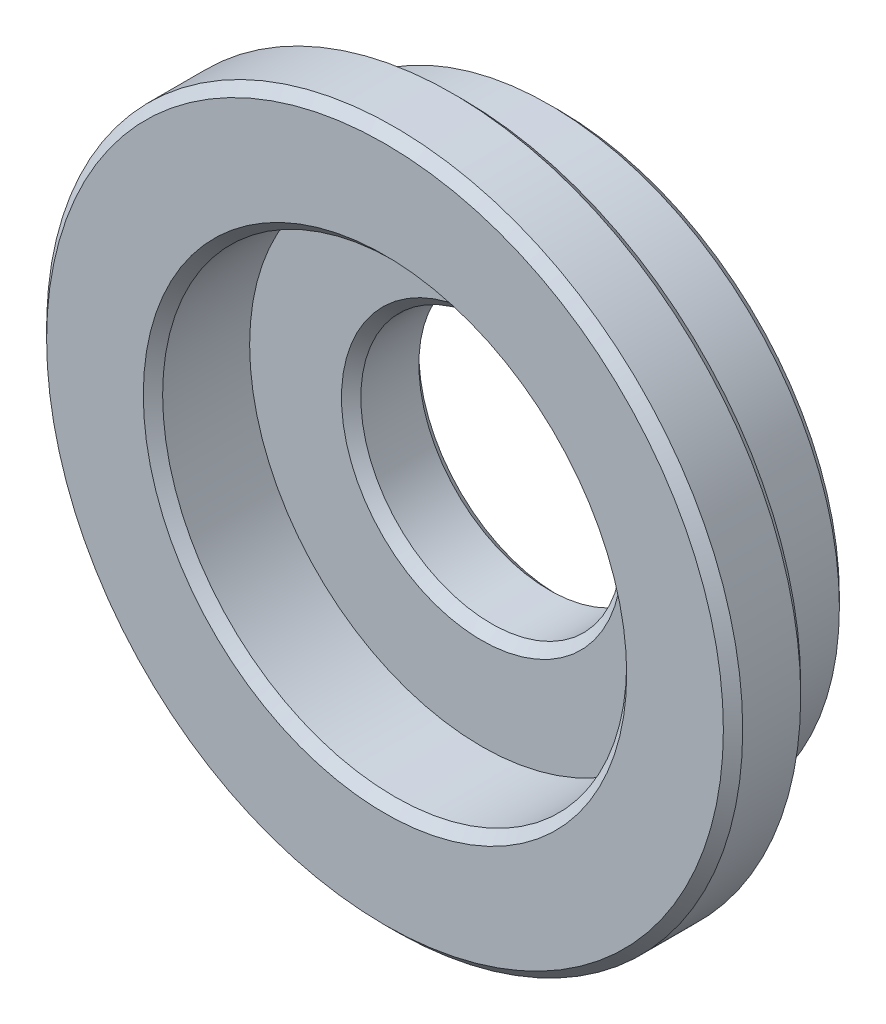
from build123d import *


with BuildPart() as part:
    # Sketch1 → Revolve1 (revolve)
    with BuildSketch(Plane(origin=(0, 0, 0), x_dir=(1, 0, 0), z_dir=(0, 1, 0))):
        Polygon((2.5, -0.8), (3.5, -0.8), (3.6, -0.7), (3.6, -0.1), (3.5, 0), (3, 0), (3, 0.9), (2.9, 1), (1.45, 1), (1.35, 0.9), (1.35, 0.3), (1.45, 0.2), (2.4, 0.2), (2.4, -0.7), align=None)
    revolve(axis=Axis((0, 0, -1), (0, 0, 1)))


solid = part.part
